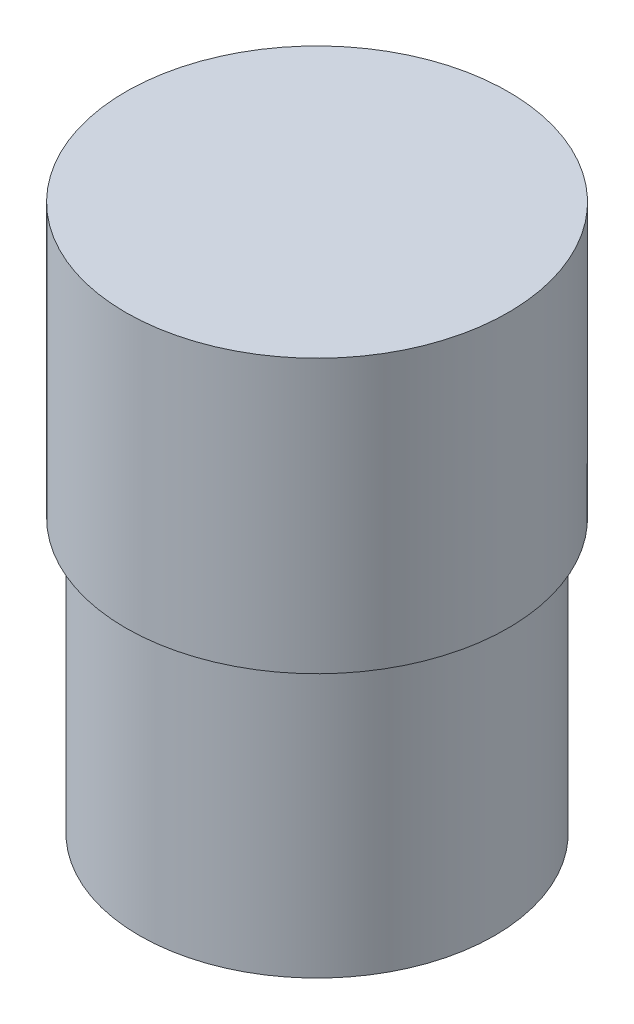
from build123d import *

# Parameters (mm, degrees)
SKETCH1_R           = 41.275
BOSS_EXTRUDE1_DEPTH = 63.5
SKETCH2_R           = 44.45
BOSS_EXTRUDE2_DEPTH = 63.5


with BuildPart() as part:
    # Sketch1 → Boss-Extrude1 (new body)
    with BuildSketch(Plane(origin=(0, 0, 0), x_dir=(1, 0, 0), z_dir=(0, 1, 0))):
        Circle(SKETCH1_R)
    extrude(amount=BOSS_EXTRUDE1_DEPTH)

    # Sketch2 → Boss-Extrude2 (add)
    with BuildSketch(Plane(origin=(0, 63.5, 0), x_dir=(1, 0, 0), z_dir=(0, 1, 0))):
        Circle(SKETCH2_R)
    extrude(amount=BOSS_EXTRUDE2_DEPTH)


solid = part.part
